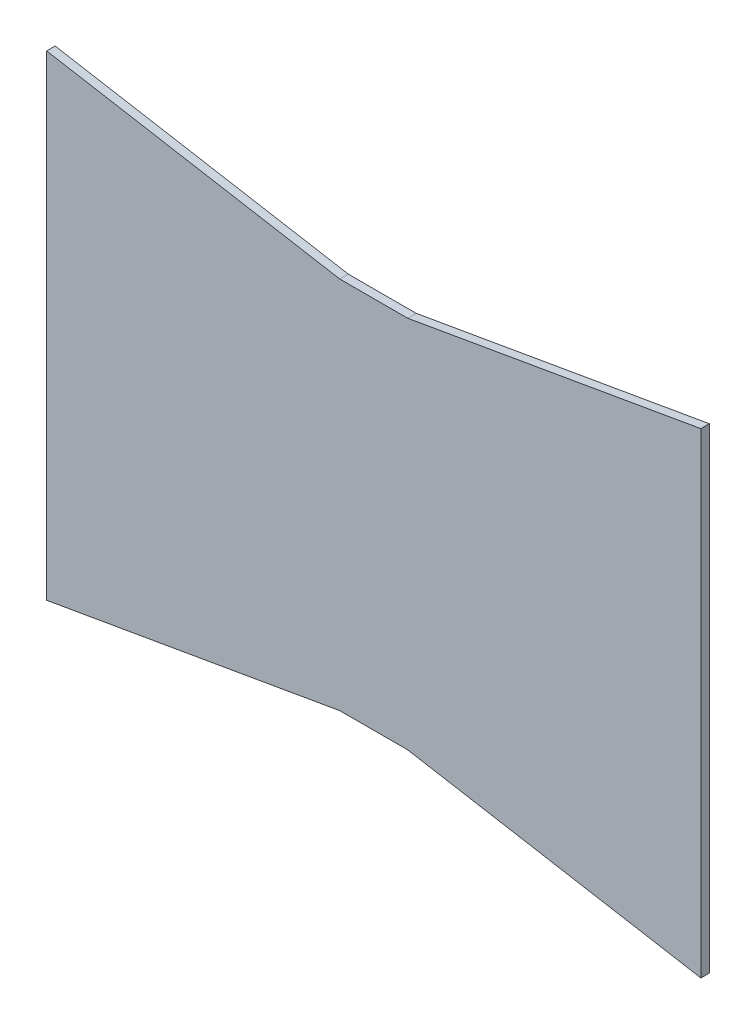
from build123d import *

# Parameters (mm, degrees)
SKETCH2_W           = 50.8
SKETCH2_H           = 279.4
BOSS_EXTRUDE2_DEPTH = 6.35


with BuildPart() as part:
    # Sketch2 → Boss-Extrude2 (new body)
    with BuildSketch(Plane.XY):
        Polygon((-25.4, -139.7), (-244.475, -177.8), (-244.475, 177.8), (-25.4, 139.7), align=None)
        Rectangle(SKETCH2_W, SKETCH2_H)
        Polygon((25.4, -139.7), (25.4, 139.7), (244.475, 177.8), (244.475, -177.8), align=None)
    extrude(amount=BOSS_EXTRUDE2_DEPTH)


solid = part.part
